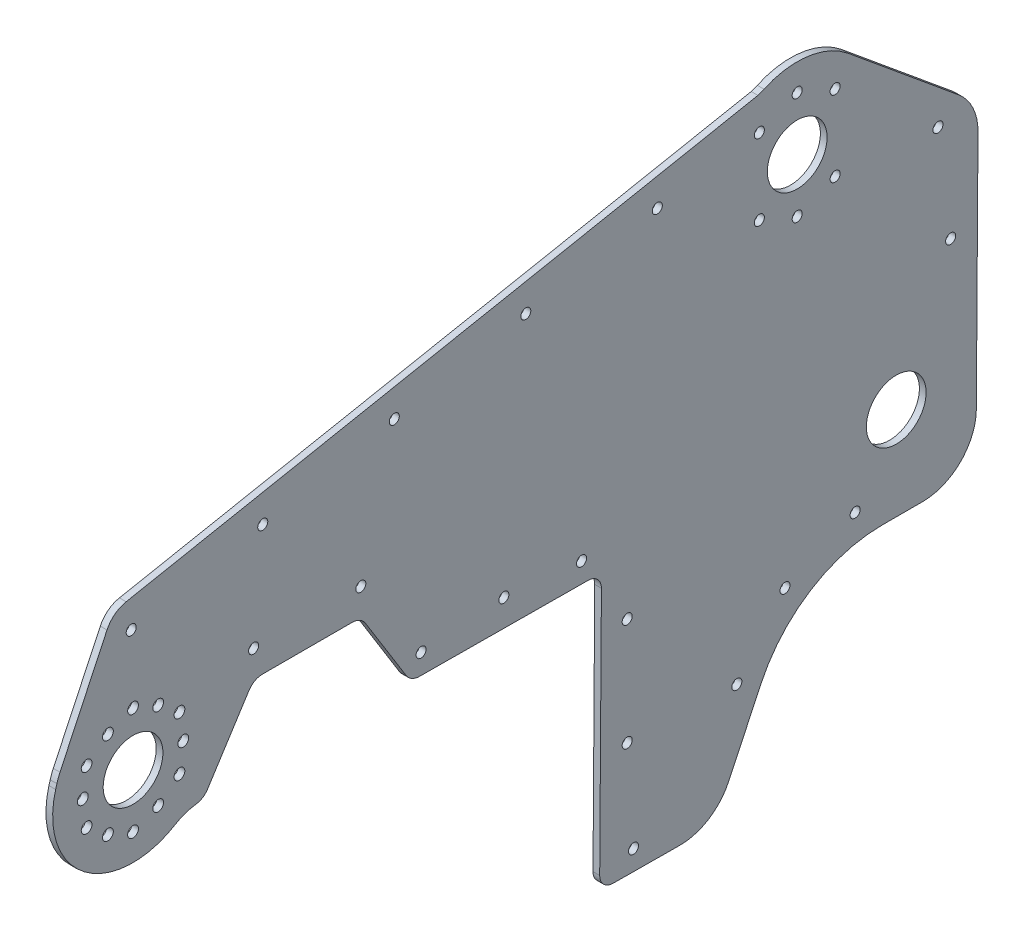
from build123d import *

# Parameters (mm, degrees)
SKETCH1_R           = 14.1605
SKETCH1_R_2         = 2.38125
BOSS_EXTRUDE2_DEPTH = 3.175
SKETCH2_R           = 2.38125
CUT_EXTRUDE1_DEPTH  = 4.175
SKETCH3_R           = 2.38125
CUT_EXTRUDE2_DEPTH  = 3.175
SKETCH6_R           = 2.5527
CUT_EXTRUDE3_DEPTH  = 4.175


with BuildPart() as part:
    # Sketch1 → Boss-Extrude2 (new body)
    with BuildSketch(Plane.ZY.offset(-2085.27445945)):
        with BuildLine():
            Line((-676.476495312, -196.108668054), (-644.862434405, -195.889095816))
            ThreePointArc((-644.862434405, -195.889095816), (-640.385331878, -193.998083759), (-638.556689771, -189.495146754))
            Line((-638.556689771, -189.495146754), (-639.372580729, -72.022980064))
            ThreePointArc((-639.372580729, -72.022980064), (-637.543938621, -67.520043059), (-633.066836095, -65.629031002))
            Line((-633.066836095, -65.629031002), (-553.190076911, -65.074255113))
            ThreePointArc((-553.190076911, -65.074255113), (-549.514401488, -64.099885183), (-546.767272269, -61.470575839))
            Line((-546.767272269, -61.470575839), (-527.590173696, -30.548905962))
            ThreePointArc((-527.590173696, -30.548905962), (-524.819944777, -27.906688623), (-521.114446397, -26.945042905))
            Line((-521.114446397, -26.945042905), (-478.726560046, -26.945042905))
            ThreePointArc((-478.726560046, -26.945042905), (-475.067517944, -27.88104628), (-472.307393362, -30.459108288))
            Line((-472.307393362, -30.459108288), (-452.701509897, -61.110700599))
            ThreePointArc((-452.701509897, -61.110700599), (-450.356282883, -63.444285805), (-447.243078231, -64.563958281))
            ThreePointArc((-447.243078231, -64.563958281), (-442.043441328, -65.791181786), (-437.215518263, -68.078857532))
            ThreePointArc((-437.215518263, -68.078857532), (-394.361205687, -65.922698326), (-380.69060226, -25.250155611))
            Line((-380.69060226, -25.250155611), (-381.274246521, -23.172734147))
            ThreePointArc((-381.274246521, -23.172734147), (-381.931013294, -21.160982924), (-382.752967438, -19.210886269))
            Line((-382.752967438, -19.210886269), (-405.028313451, 28.035268168))
            ThreePointArc((-405.028313451, 28.035268168), (-408.719025679, 32.64446469), (-414.095120009, 35.086525107))
            Line((-414.095120009, 35.086525107), (-713.524757665, 93.219773114))
            ThreePointArc((-713.524757665, 93.219773114), (-714.988859477, 93.729040419), (-716.419168956, 94.326670824))
            ThreePointArc((-716.419168956, 94.326670824), (-737.189413392, 97.405032689), (-756.436338691, 89.012462628))
            Line((-756.436338691, 89.012462628), (-808.634266444, 45.900443365))
            ThreePointArc((-808.634266444, 45.900443365), (-815.475018373, 37.06060929), (-817.858650965, 26.140130862))
            Line((-817.858650965, 26.140130862), (-817.070267282, -87.371532031))
            ThreePointArc((-817.070267282, -87.371532031), (-809.568913511, -105.217897447), (-791.670879889, -112.595123175))
            Line((-791.670879889, -112.595123175), (-772.445079401, -112.595123175))
            ThreePointArc((-772.445079401, -112.595123175), (-738.471128747, -122.447936138), (-715.040138137, -148.948802642))
            Line((-715.040138137, -148.948802642), (-699.614880674, -181.567808874))
            ThreePointArc((-699.614880674, -181.567808874), (-690.167883624, -192.215217755), (-676.476495312, -196.108668054))
        make_face()
        with Locations((-732.173834383, 59.636607157)):
            Circle(SKETCH1_R, mode=Mode.SUBTRACT)
        with Locations((-779.099930223, -68.570323835)):
            Circle(SKETCH1_R, mode=Mode.SUBTRACT)
        with Locations((-654.585392145, -186.431395895)):
            Circle(SKETCH1_R_2, mode=Mode.SUBTRACT)
        with Locations((-629.958065992, -56.082209622)):
            Circle(SKETCH1_R_2, mode=Mode.SUBTRACT)
        with Locations((-553.895503221, -55.553924847)):
            Circle(SKETCH1_R_2, mode=Mode.SUBTRACT)
        with Locations((-417.370503221, -35.55524491)):
            Circle(SKETCH1_R, mode=Mode.SUBTRACT)
    extrude(amount=BOSS_EXTRUDE2_DEPTH)

    # Sketch2 → Cut-Extrude1 (cut, through all)
    with BuildSketch(Plane(origin=(2085.27445945, 0, 0), x_dir=(0, 0, -1), z_dir=(1, 0, 0))):
        with Locations((732.173834383, 85.036607157)):
            Circle(SKETCH2_R)
        with Locations((732.173834383, 34.236607157)):
            Circle(SKETCH2_R)
        with Locations((750.134264867, 41.676013157)):
            Circle(SKETCH2_R)
        with Locations((714.213403899, 77.597201157)):
            Circle(SKETCH2_R)
        with Locations((750.134264867, 77.597201157)):
            Circle(SKETCH2_R)
        with Locations((714.213403899, 41.676013157)):
            Circle(SKETCH2_R)
    extrude(amount=-CUT_EXTRUDE1_DEPTH, mode=Mode.SUBTRACT)

    # Sketch3 → Cut-Extrude2 (cut)
    with BuildSketch(Plane(origin=(2085.27445945, 0, 0), x_dir=(0, 0, -1), z_dir=(1, 0, 0))):
        with Locations((759.618090186, -100.982485439)):
            Circle(SKETCH3_R)
        with Locations((541.187693092, 46.53204311)):
            Circle(SKETCH3_R)
        with Locations((478.851639869, 34.42970992)):
            Circle(SKETCH3_R)
        with Locations((416.515586647, 22.327376731)):
            Circle(SKETCH3_R)
        with Locations((525.320503221, -14.245042905)):
            Circle(SKETCH3_R)
        with Locations((798.886947172, 37.479390763)):
            Circle(SKETCH3_R)
        with Locations((665.859799537, 70.736709489)):
            Circle(SKETCH3_R)
        with Locations((603.523746314, 58.634376299)):
            Circle(SKETCH3_R)
        with Locations((703.559149884, -143.519538535)):
            Circle(SKETCH3_R)
        with Locations((726.384244699, -115.392244277)):
            Circle(SKETCH3_R)
        with Locations((804.898658391, -11.249556635)):
            Circle(SKETCH3_R)
        with Locations((474.520503221, -14.245042905)):
            Circle(SKETCH3_R)
        with Locations((651.589984927, -141.551336746)):
            Circle(SKETCH3_R)
        with Locations((651.589984927, -90.751336746)):
            Circle(SKETCH3_R)
        with Locations((593.128456503, -52.651336746)):
            Circle(SKETCH3_R)
    extrude(amount=-CUT_EXTRUDE2_DEPTH, mode=Mode.SUBTRACT)

    # Sketch6 → Cut-Extrude3 (cut, through all)
    with BuildSketch(Plane(origin=(2085.27445945, 0, 0), x_dir=(0, 0, -1), z_dir=(1, 0, 0))):
        with Locations((395.373457966, -48.25524491)):
            Circle(SKETCH6_R)
        with Locations((405.464253222, -56.177474837)):
            Circle(SKETCH6_R)
        with Locations((395.373457966, -22.85524491)):
            Circle(SKETCH6_R)
        with Locations((393.558003223, -35.55524491)):
            Circle(SKETCH6_R)
        with Locations((417.370503221, -10.15524491)):
            Circle(SKETCH6_R)
        with Locations((405.464253222, -14.933014983)):
            Circle(SKETCH6_R)
        with Locations((439.367548477, -22.85524491)):
            Circle(SKETCH6_R)
        with Locations((429.276753221, -14.933014983)):
            Circle(SKETCH6_R)
        with Locations((439.367548477, -48.25524491)):
            Circle(SKETCH6_R)
        with Locations((441.18300322, -35.55524491)):
            Circle(SKETCH6_R)
        with Locations((417.370503221, -60.95524491)):
            Circle(SKETCH6_R)
        with Locations((429.276753221, -56.177474837)):
            Circle(SKETCH6_R)
    extrude(amount=-CUT_EXTRUDE3_DEPTH, mode=Mode.SUBTRACT)


solid = part.part
